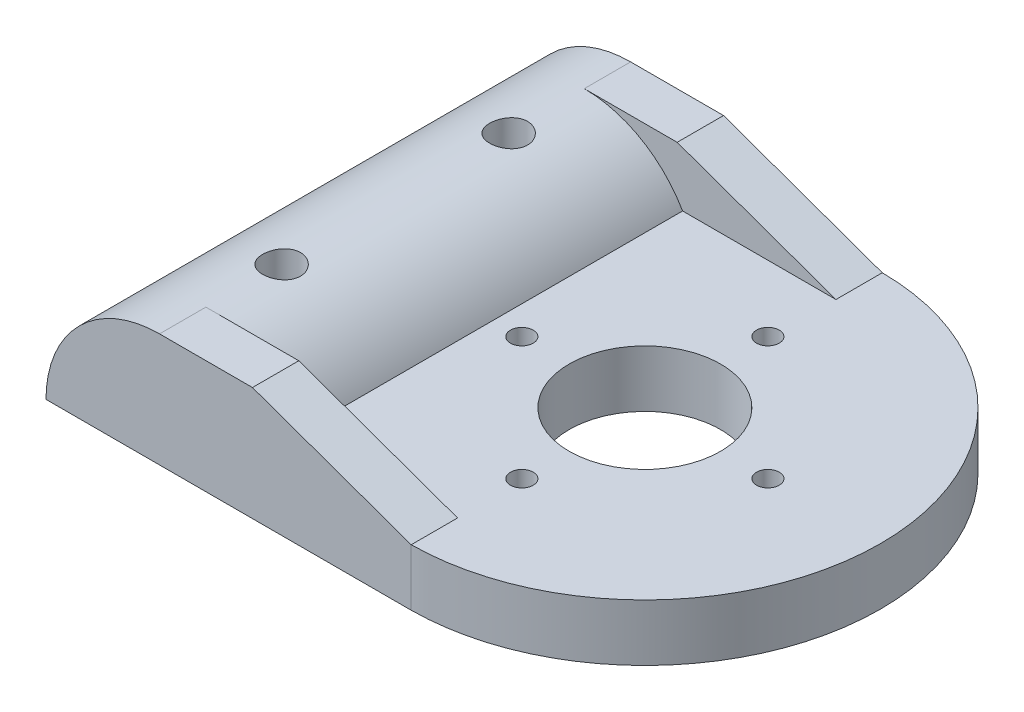
from build123d import *

# Parameters (mm, degrees)
CROQUIS1_R              = 0.599999868
CROQUIS1_R_2            = 3.999426158
CROQUIS1_R_3            = 1.000000121
CROQUIS1_R_4            = 1.000000477
SALIENTE_EXTRUIR1_DEPTH = 3
SALIENTE_EXTRUIR2_DEPTH = 24.89496
CROQUIS3_W              = 13.299999714
CROQUIS3_H              = 2.45
SALIENTE_EXTRUIR3_DEPTH = 3
CORTAR_EXTRUIR1_DEPTH   = 24.89496
CROQUIS5_R              = 1.000000121
CROQUIS5_R_2            = 1.000000477
CORTAR_EXTRUIR2_DEPTH   = 11


with BuildPart() as part:
    # Croquis1 → Saliente-Extruir1 (new body)
    with BuildSketch(Plane(origin=(0, 0, 0), x_dir=(1, 0, 0), z_dir=(0, 1, 0))):
        with BuildLine():
            Line((4.218422555, -12.81969876), (-15.081577159, -12.81969876))
            Line((-15.081577159, -12.81969876), (-15.081577159, 12.075260967))
            Line((-15.081577159, 12.075260967), (4.218422555, 12.075260967))
            ThreePointArc((4.218422555, 12.075260967), (16.567050884, -0.372218896), (4.218422555, -12.81969876))
        make_face()
        with Locations((4.118422395, 6.128403493)):
            Circle(CROQUIS1_R, mode=Mode.SUBTRACT)
        with Locations((4.119175364, -0.372218896)):
            Circle(CROQUIS1_R_2, mode=Mode.SUBTRACT)
        with Locations((-9.081577367, 5.628403394)):
            Circle(CROQUIS1_R_3, mode=Mode.SUBTRACT)
        with Locations((-9.081576585, -6.371596672)):
            Circle(CROQUIS1_R_4, mode=Mode.SUBTRACT)
        with Locations((10.620712828, -0.371667036)):
            Circle(CROQUIS1_R, mode=Mode.SUBTRACT)
        with Locations((4.1206423, -6.873957469)):
            Circle(CROQUIS1_R, mode=Mode.SUBTRACT)
        with Locations((-2.381648134, -0.373886941)):
            Circle(CROQUIS1_R, mode=Mode.SUBTRACT)
    extrude(amount=SALIENTE_EXTRUIR1_DEPTH)

    # Croquis2 → Saliente-Extruir2 (add)
    with BuildSketch(Plane.XY.offset(12.81969876)):
        with BuildLine():
            Line((-14.277729582, 3), (-3.885424736, 3))
            ThreePointArc((-3.885424736, 3), (-9.081577159, 6), (-14.277729582, 3))
        make_face()
    extrude(amount=-SALIENTE_EXTRUIR2_DEPTH)

    # Croquis3 → Saliente-Extruir3 (add)
    with BuildSketch(Plane(origin=(0, 3, 0), x_dir=(1, 0, 0), z_dir=(0, 1, 0))):
        with Locations((-2.431577302, -11.59469876)):
            Rectangle(CROQUIS3_W, CROQUIS3_H)
        with Locations((-2.431577302, 10.850260967)):
            Rectangle(CROQUIS3_W, CROQUIS3_H)
    extrude(amount=SALIENTE_EXTRUIR3_DEPTH)

    # Croquis4 → Cortar-Extruir1 (cut)
    with BuildSketch(Plane.XY.offset(12.81969876)):
        Polygon((-4.171577445, 6), (4.218422555, 3), (4.218422555, 6), align=None)
        with BuildLine():
            Line((-15.081577159, 0), (-16.256016644, 0))
            ThreePointArc((-16.256016644, 0), (-14.36312843, 4.855697487), (-9.683294652, 7.149162047))
            Line((-9.683294652, 7.149162047), (-9.683294652, 5.969751759))
            ThreePointArc((-9.683294652, 5.969751759), (-13.53187518, 4.024282237), (-15.081577159, 0))
        make_face()
    extrude(amount=-CORTAR_EXTRUIR1_DEPTH, mode=Mode.SUBTRACT)

    # Croquis5 → Cortar-Extruir2 (cut)
    with BuildSketch(Plane.XZ):
        with Locations((-9.081577367, -5.628403394)):
            Circle(CROQUIS5_R)
        with Locations((-9.081576585, 6.371596672)):
            Circle(CROQUIS5_R_2)
    extrude(amount=-CORTAR_EXTRUIR2_DEPTH, mode=Mode.SUBTRACT)


solid = part.part
